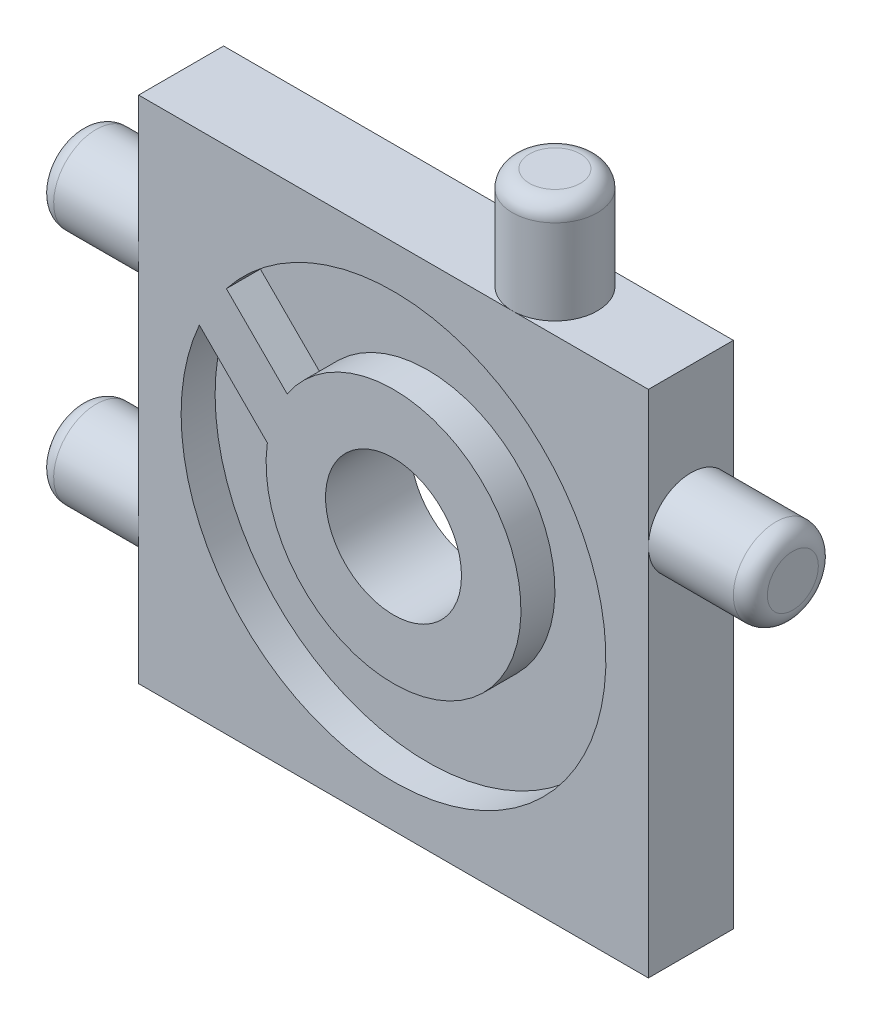
from build123d import *

# Parameters (mm, degrees)
ESQUISSE2_W              = 30
ESQUISSE2_H              = 30
BOSS_EXTRU_1_DEPTH       = 5
ESQUISSE16_R             = 2.5
BOSS_EXTRU_7_DEPTH       = 6
CONG_3_R                 = 1
ESQUISSE18_R             = 2.5
BOSS_EXTRU_9_DEPTH       = 6
CONG_5_R                 = 1
ESQUISSE8_R              = 12.5
ENL_V_MAT_EXTRU_1_DEPTH  = 2
ESQUISSE19_R             = 7.5
BOSS_EXTRU_10_DEPTH      = 2
ESQUISSE33_R             = 4
ENL_V_MAT_EXTRU_3_DEPTH  = 6
ESQUISSE35_R             = 2.5
BOSS_EXTRU_26_DEPTH      = 6
CONG_6_R                 = 1
BOSS_EXTRU_27_DEPTH      = 2
BOSS_EXTRU_27_DEPTH_BACK = 5.5


with BuildPart() as part:
    # Esquisse2 → Boss.-Extru.1 (new body)
    with BuildSketch(Plane.XY):
        Rectangle(ESQUISSE2_W, ESQUISSE2_H)
    extrude(amount=BOSS_EXTRU_1_DEPTH)

    # Esquisse16 → Boss.-Extru.7 (add)
    with BuildSketch(Plane.ZY.offset(15)):
        with Locations((2.5, 7)):
            Circle(ESQUISSE16_R)
        with Locations((2.5, -7)):
            Circle(ESQUISSE16_R)
    extrude(amount=BOSS_EXTRU_7_DEPTH)

    # Congé3
    cong_3_edges = [part.edges().sort_by_distance(p)[0] for p in [
        (-21, 7, 0),
        (-21, -7, 0),
    ]]
    fillet(cong_3_edges, radius=CONG_3_R)

    # Esquisse18 → Boss.-Extru.9 (add)
    with BuildSketch(Plane(origin=(15, 0, 0), x_dir=(0, 0, -1), z_dir=(1, 0, 0))):
        with Locations((-2.5, 7)):
            Circle(ESQUISSE18_R)
    extrude(amount=BOSS_EXTRU_9_DEPTH)

    # Congé5
    cong_5_edges = [part.edges().sort_by_distance(p)[0] for p in [
        (21, 7, 5),
    ]]
    fillet(cong_5_edges, radius=CONG_5_R)

    # Esquisse8 → Enlèv. mat.-Extru.1 (cut)
    with BuildSketch(Plane.XY.offset(5)):
        Circle(ESQUISSE8_R)
    extrude(amount=-ENL_V_MAT_EXTRU_1_DEPTH, mode=Mode.SUBTRACT)

    # Esquisse19 → Boss.-Extru.10 (add)
    with BuildSketch(Plane.XY.offset(3)):
        Circle(ESQUISSE19_R)
    extrude(amount=BOSS_EXTRU_10_DEPTH)

    # Esquisse33 → Enlèv. mat.-Extru.3 (cut, through all)
    with BuildSketch(Plane.XY.offset(5)):
        Circle(ESQUISSE33_R)
    extrude(amount=-ENL_V_MAT_EXTRU_3_DEPTH, mode=Mode.SUBTRACT)

    # Esquisse35 → Boss.-Extru.26 (add)
    with BuildSketch(Plane(origin=(0, 15, 0), x_dir=(1, 0, 0), z_dir=(0, 1, 0))):
        with Locations((7, -2.5)):
            Circle(ESQUISSE35_R)
    extrude(amount=BOSS_EXTRU_26_DEPTH)

    # Congé6
    cong_6_edges = [part.edges().sort_by_distance(p)[0] for p in [
        (4.5, 21, 2.5),
    ]]
    fillet(cong_6_edges, radius=CONG_6_R)

    # Esquisse31 → Boss.-Extru.27 (add, two sides)
    with BuildSketch(Plane.XY.offset(3)) as boss_extru_27_sk:
        Polygon((-12.02081528, 5.656854249), (-9.899494937, 7.778174593), (-4.937341349, 2.816021005), (-7.058661692, 0.694700662), align=None)
    extrude(amount=BOSS_EXTRU_27_DEPTH)
    extrude(boss_extru_27_sk.sketch, amount=-BOSS_EXTRU_27_DEPTH_BACK)


solid = part.part
